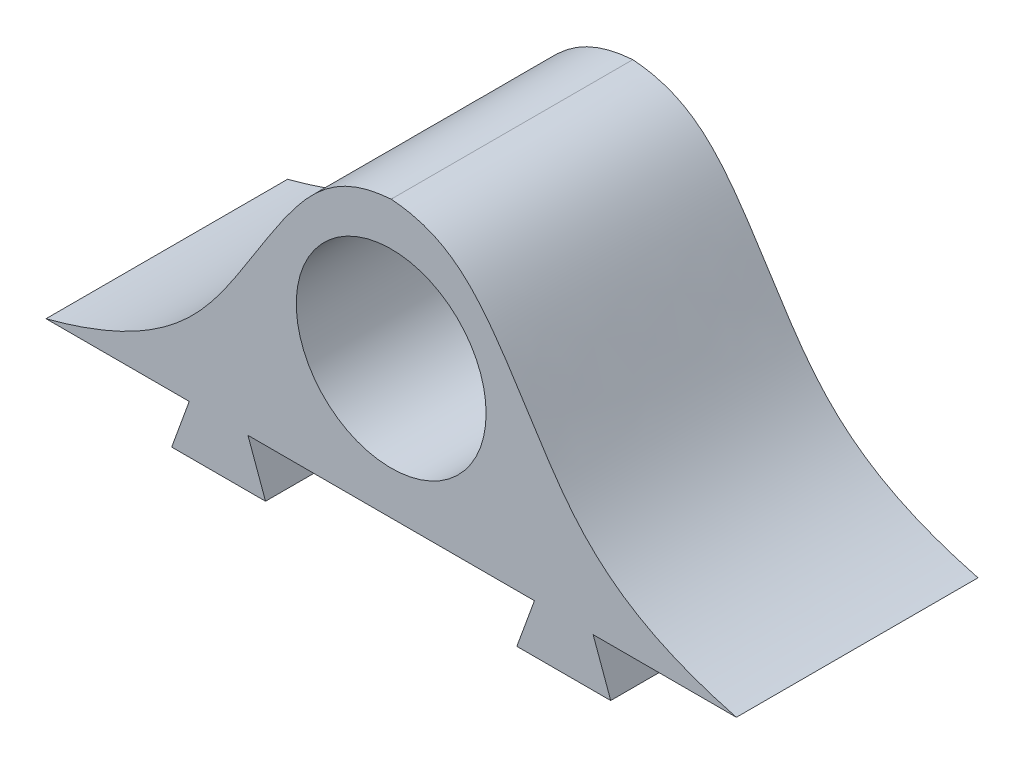
from build123d import *

# Parameters (mm, degrees)
SKETCH_1_R          = 2.75
EXTRUDE_1_DEPTH     = 7
CUT_EXTRUDE_1_DEPTH = 6.5


with BuildPart() as part:
    # 草圖1 → 填料-伸長1 (new body)
    with BuildSketch(Plane.XY):
        with BuildLine():
            Line((-10, 0), (-5.85, 0))
            Line((-5.85, 0), (-6.359558328, -1.4))
            Line((-6.359558328, -1.4), (-3.640441672, -1.4))
            Line((-3.640441672, -1.4), (-4.15, 0))
            Line((-4.15, 0), (4.15, 0))
            Line((4.15, 0), (3.640441672, -1.4))
            Line((3.640441672, -1.4), (6.359558328, -1.4))
            Line((6.359558328, -1.4), (5.85, 0))
            Line((5.85, 0), (10, 0))
            add(Edge.make_bspline(
                [(10, 0), (6.506599927, 0.91468669), (5.142438062, 2.759694825), (2.700884336, 6.654283479), (1.746574016, 7.868913283), (0, 8)],
                knots=[0, 0, 0, 0, 0.426505947, 0.526505947, 1, 1, 1, 1], degree=3))
            add(Edge.make_bspline(
                [(-10, 0), (-6.506599927, 0.91468669), (-5.142438062, 2.759694825), (-2.700884336, 6.654283479), (-1.746574016, 7.868913283), (0, 8)],
                knots=[0, 0, 0, 0, 0.426505947, 0.526505947, 1, 1, 1, 1], degree=3))
        make_face()
        with Locations((0, 4)):
            Circle(SKETCH_1_R, mode=Mode.SUBTRACT)
    extrude(amount=EXTRUDE_1_DEPTH)

    # 草圖2 → 除料-伸長1 (cut, symmetric)
    with BuildSketch(Plane(origin=(0, 0, 0), x_dir=(0, 0, -1), z_dir=(1, 0, 0))):
        with BuildLine():
            Line((-1.9, -1.4), (-1.1, -1.4))
            ThreePointArc((-1.1, -1.4), (-1.5, -1.264313215), (-1.9, -1.4))
        make_face()
    extrude(amount=CUT_EXTRUDE_1_DEPTH, both=True, mode=Mode.SUBTRACT)


solid = part.part
